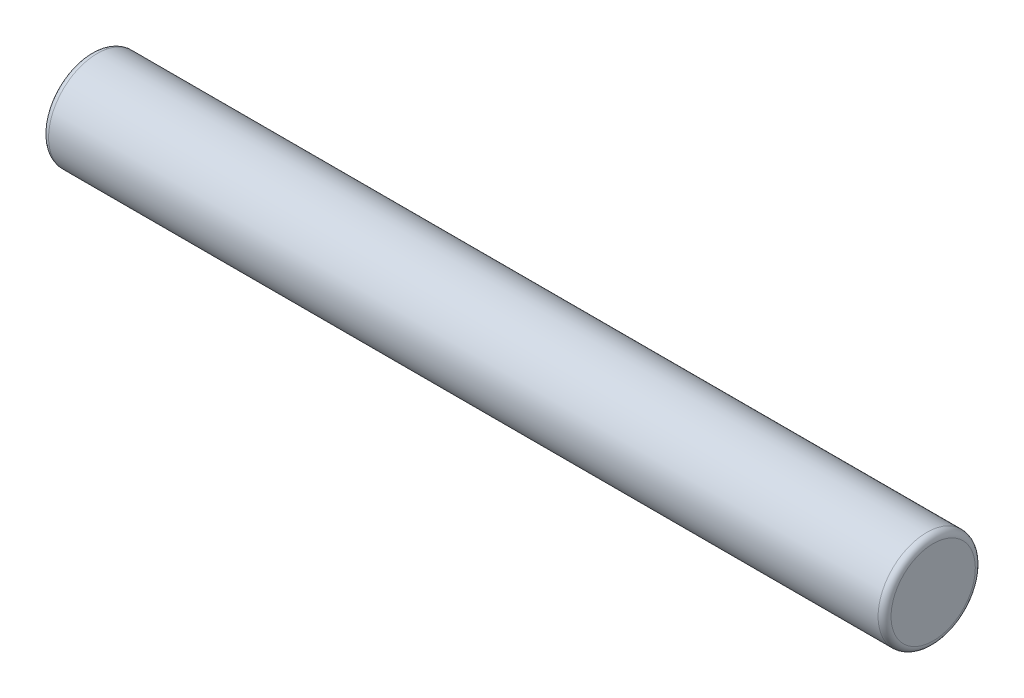
from build123d import *

# Parameters (mm, degrees)
SKETCH1_R           = 1.5
BOSS_EXTRUDE1_DEPTH = 13
FILLET1_R           = 0.2


with BuildPart() as part:
    # Sketch1 → Boss-Extrude1 (new body, symmetric)
    with BuildSketch(Plane(origin=(0, 0, 0), x_dir=(0, 0, -1), z_dir=(1, 0, 0))):
        Circle(SKETCH1_R)
    extrude(amount=BOSS_EXTRUDE1_DEPTH, both=True)

    # Fillet1
    fillet1_edges = [part.edges().sort_by_distance(p)[0] for p in [
        (-13, 0, 1.5),
        (13, 0, 1.5),
    ]]
    fillet(fillet1_edges, radius=FILLET1_R)


solid = part.part
